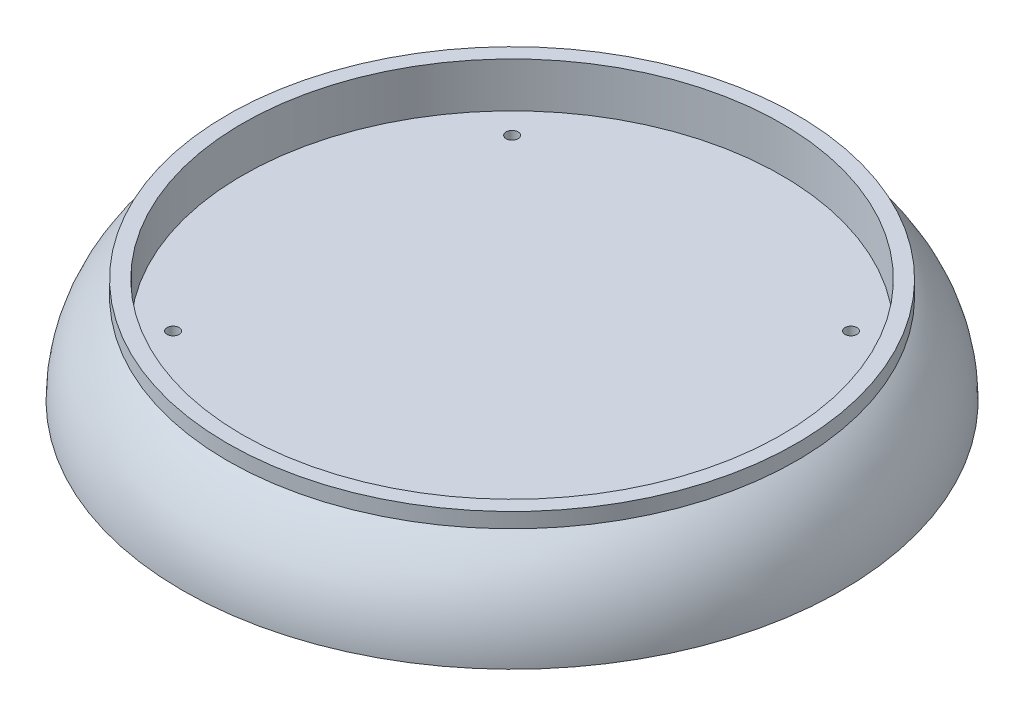
from build123d import *

# Parameters (mm, degrees)
SKETCH1_R          = 2
CUT_EXTRUDE1_DEPTH = 21


with BuildPart() as part:
    # Sketch2 → Revolve1 (revolve)
    with BuildSketch(Plane.XY):
        with BuildLine():
            Line((90, 0), (90, 15))
            Line((90, 15), (95, 15))
            Line((95, 15), (95, 10))
            ThreePointArc((95, 10), (106.041019662, -3.229490169), (110, -20))
            Line((110, -20), (0, -20))
            Line((0, -20), (0, 0))
            Line((0, 0), (90, 0))
        make_face()
    revolve(axis=Axis((0, 0, 0), (0, -1, 0)))

    # Sketch1 → Cut-Extrude1 (cut, through all)
    with BuildSketch(Plane(origin=(0, 0, 0), x_dir=(1, 0, 0), z_dir=(0, 1, 0))):
        with Locations((-56.568542495, 56.568542495)):
            Circle(SKETCH1_R)
        with Locations((-56.568542495, -56.568542495)):
            Circle(SKETCH1_R)
        with Locations((56.568542495, 56.568542495)):
            Circle(SKETCH1_R)
        with Locations((56.568542495, -56.568542495)):
            Circle(SKETCH1_R)
    extrude(amount=-CUT_EXTRUDE1_DEPTH, mode=Mode.SUBTRACT)


solid = part.part
